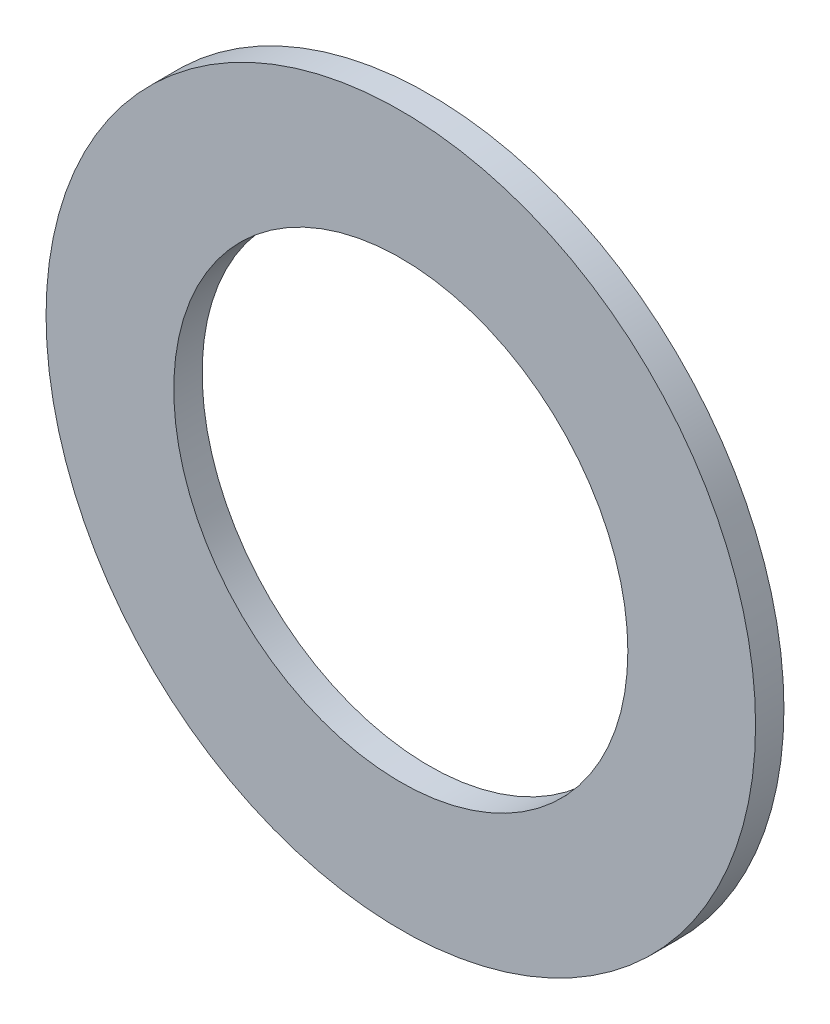
from build123d import *

# Parameters (mm, degrees)
SKETCH1_R      = 3.175
SKETCH1_R_2    = 2.032
EXTRUDE1_DEPTH = 0.254


with BuildPart() as part:
    # Sketch1 → Extrude1 (new body)
    with BuildSketch(Plane.XY):
        Circle(SKETCH1_R)
        Circle(SKETCH1_R_2, mode=Mode.SUBTRACT)
    extrude(amount=-EXTRUDE1_DEPTH)


solid = part.part
